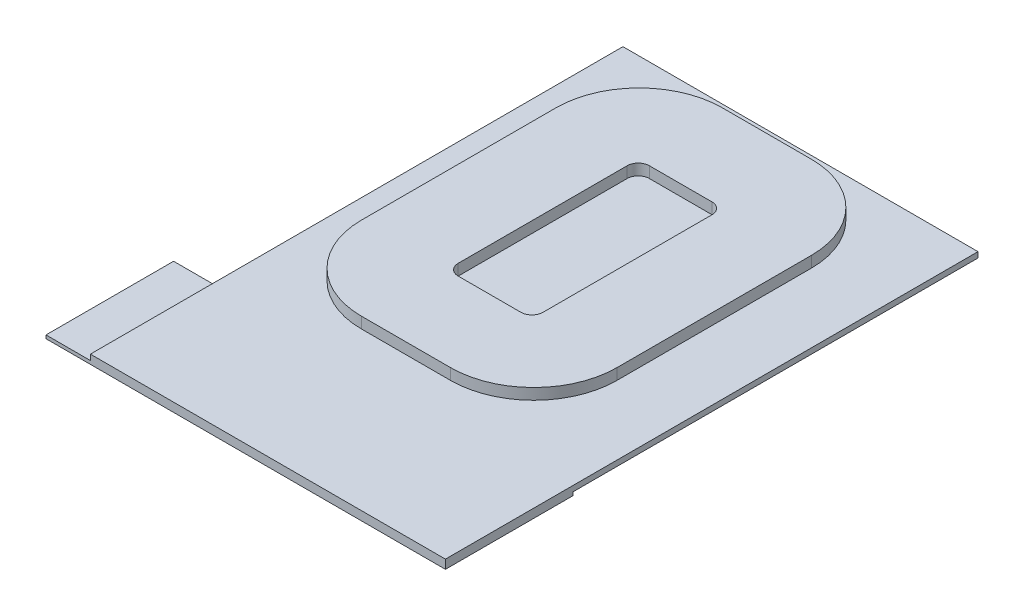
from build123d import *

# Parameters (mm, degrees)
SKETCH1_W           = 32
SKETCH1_H           = 48
BOSS_EXTRUDE1_DEPTH = 0.5
BOSS_EXTRUDE2_DEPTH = 1
SKETCH3_W           = 36
SKETCH3_H           = 11.5
BOSS_EXTRUDE3_DEPTH = 0.3


with BuildPart() as part:
    # Sketch1 → Boss-Extrude1 (new body)
    with BuildSketch(Plane(origin=(0, 0, 0), x_dir=(1, 0, 0), z_dir=(0, 1, 0))):
        Rectangle(SKETCH1_W, SKETCH1_H)
    extrude(amount=BOSS_EXTRUDE1_DEPTH)

    # Sketch2 → Boss-Extrude2 (add)
    with BuildSketch(Plane(origin=(0, 0.5, 0), x_dir=(1, 0, 0), z_dir=(0, 1, 0))):
        with BuildLine():
            Line((-5.744434592, 22.704745015), (2.282363543, 22.704745015))
            ThreePointArc((2.282363543, 22.704745015), (7.585664402, 20.508045873), (9.782363543, 15.204745015))
            Line((9.782363543, 15.204745015), (9.782363543, -2.322620184))
            ThreePointArc((9.782363543, -2.322620184), (7.585664402, -7.625921042), (2.282363543, -9.822620184))
            Line((2.282363543, -9.822620184), (-5.744434592, -9.822620184))
            ThreePointArc((-5.744434592, -9.822620184), (-11.047735451, -7.625921042), (-13.244434592, -2.322620184))
            Line((-13.244434592, -2.322620184), (-13.244434592, 15.204745015))
            ThreePointArc((-13.244434592, 15.204745015), (-11.047735451, 20.508045873), (-5.744434592, 22.704745015))
        make_face()
        with BuildLine():
            Line((-4.515159693, 14.894956836), (1.133601925, 14.894956836))
            ThreePointArc((1.133601925, 14.894956836), (1.840708706, 14.602063617), (2.133601925, 13.894956836))
            Line((2.133601925, 13.894956836), (2.133601925, -1.334885126))
            ThreePointArc((2.133601925, -1.334885126), (1.840708706, -2.041991907), (1.133601925, -2.334885126))
            Line((1.133601925, -2.334885126), (-4.515159693, -2.334885126))
            ThreePointArc((-4.515159693, -2.334885126), (-5.222266474, -2.041991907), (-5.515159693, -1.334885126))
            Line((-5.515159693, -1.334885126), (-5.515159693, 13.894956836))
            ThreePointArc((-5.515159693, 13.894956836), (-5.222266474, 14.602063617), (-4.515159693, 14.894956836))
        make_face(mode=Mode.SUBTRACT)
    extrude(amount=BOSS_EXTRUDE2_DEPTH)

    # Sketch3 → Boss-Extrude3 (add)
    with BuildSketch(Plane.XZ):
        with Locations((-2, 18.25)):
            Rectangle(SKETCH3_W, SKETCH3_H)
    extrude(amount=BOSS_EXTRUDE3_DEPTH)


solid = part.part
